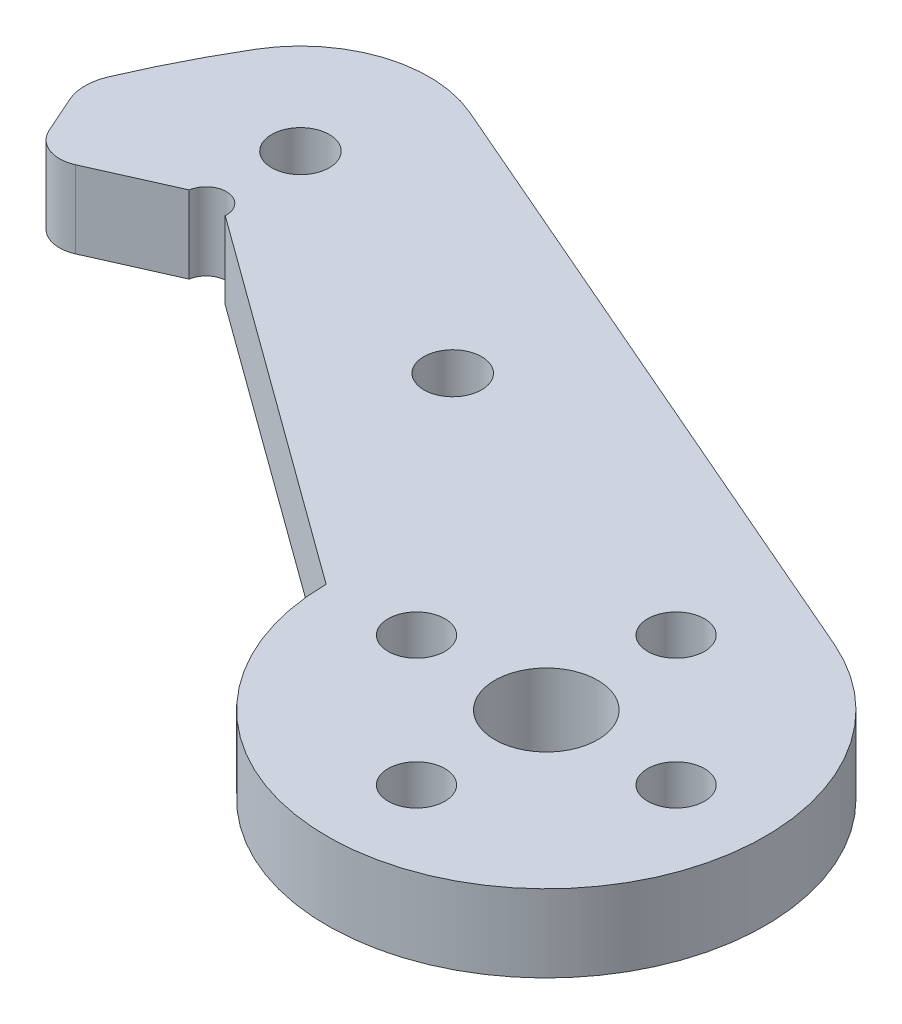
from build123d import *

# Parameters (mm, degrees)
SKETCH1_R           = 1.75
SKETCH1_R_2         = 3.175
SKETCH1_R_3         = 1.778
BOSS_EXTRUDE1_DEPTH = 4.7625


with BuildPart() as part:
    # Sketch1 → Boss-Extrude1 (new body)
    with BuildSketch(Plane(origin=(0, 0, 0), x_dir=(1, 0, 0), z_dir=(0, 1, 0))):
        with BuildLine():
            Line((-38.770225031, 16.757963615), (-43.625448569, 14.598747375))
            ThreePointArc((-43.625448569, 14.598747375), (-45.155674622, 14.559326862), (-46.265582353, 15.613485569))
            Line((-46.265582353, 15.613485569), (-47.282683039, 17.900542834))
            ThreePointArc((-47.282683039, 17.900542834), (-47.541465806, 19.100109045), (-47.298283286, 20.302934833))
            ThreePointArc((-47.298283286, 20.302934833), (-45.865213893, 23.360627542), (-44.234733225, 26.317772344))
            ThreePointArc((-44.234733225, 26.317772344), (-39.855484626, 29.811728531), (-34.259632886, 29.543416329))
            Line((-34.259632886, 29.543416329), (5.363638877, 12.388760148))
            ThreePointArc((5.363638877, 12.388760148), (7.44200849, -11.263503435), (-13.499793526, -0.074664302))
            Line((-13.499793526, -0.074664302), (-36.286855081, 16.495885282))
            ThreePointArc((-36.286855081, 16.495885282), (-37.403602541, 17.810792136), (-38.770225031, 16.757963615))
        make_face()
        with Locations((8, 0)):
            Circle(SKETCH1_R, mode=Mode.SUBTRACT)
        with Locations((0, -8)):
            Circle(SKETCH1_R, mode=Mode.SUBTRACT)
        with Locations((-8, 0)):
            Circle(SKETCH1_R, mode=Mode.SUBTRACT)
        with Locations((0, 8)):
            Circle(SKETCH1_R, mode=Mode.SUBTRACT)
        Circle(SKETCH1_R_2, mode=Mode.SUBTRACT)
        with Locations((-20.862458922, 15.093717491)):
            Circle(SKETCH1_R_3, mode=Mode.SUBTRACT)
        with Locations((-37.413253893, 22.259284205)):
            Circle(SKETCH1_R_3, mode=Mode.SUBTRACT)
    extrude(amount=BOSS_EXTRUDE1_DEPTH)


solid = part.part
